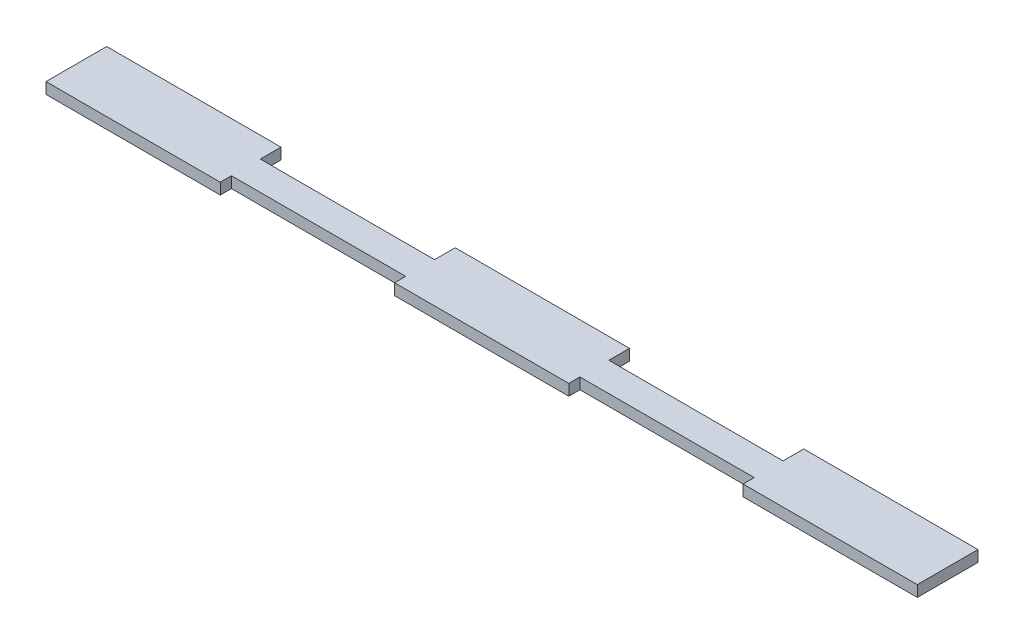
from build123d import *

# Parameters (mm, degrees)
BOSS_EXTRUDE1_DEPTH = 2.7


with BuildPart() as part:
    # Sketch1 → Boss-Extrude1 (new body)
    with BuildSketch(Plane(origin=(0, 0, 0), x_dir=(1, 0, 0), z_dir=(0, 1, 0))):
        Polygon((-63.3, 3.6875768), (-21.1, 3.6875768), (-21.1, 8.6875768), (21.1, 8.6875768), (21.1, 3.6875768), (63.3, 3.6875768), (63.3, 8.6875768), (105.5, 8.6875768), (105.5, -6.0124232), (63.3, -6.0124232), (63.3, -3.3124232), (21.1, -3.3124232), (21.1, -6.0124232), (-21.1, -6.0124232), (-21.1, -3.3124232), (-63.3, -3.3124232), (-63.3, -6.0124232), (-105.5, -6.0124232), (-105.5, 8.6875768), (-63.3, 8.6875768), align=None)
    extrude(amount=BOSS_EXTRUDE1_DEPTH)


solid = part.part
